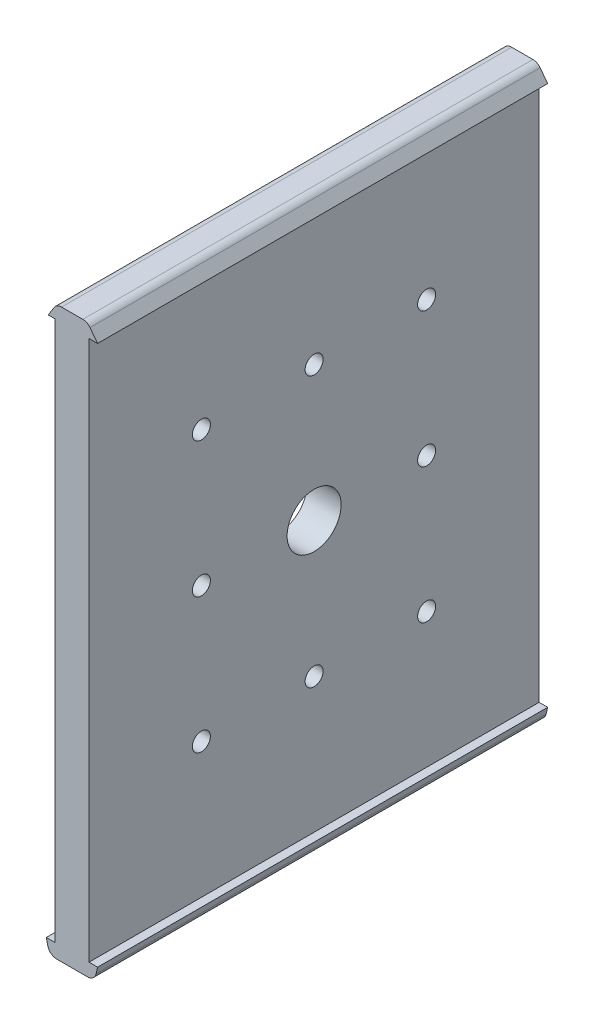
from build123d import *

# Parameters (mm, degrees)
RESSALTO_EXTRUS_O1_DEPTH   = 160
ESBO_O2_W                  = 7.6
ESBO_O2_H                  = 120
CORTE_EXTRUS_O1_DEPTH      = 30
CORTE_EXTRUS_O2_DEPTH      = 30
F_3DSKETCH3_R              = 2
CORTE_EXTRUS_O3_DEPTH      = 70
ESBO_O3_R                  = 6
ESBO_O3_W                  = 45.015344868
ESBO_O3_H                  = 129.478543367
ESBO_O3_W_2                = 37.192593828
CORTE_EXTRUS_O4_DEPTH      = 41
CORTE_EXTRUS_O4_DEPTH_BACK = 22


with BuildPart() as part:
    # Esboço1 → Ressalto-extrusão1 (new body)
    with BuildSketch(Plane.XY):
        with BuildLine():
            Line((-3.8, 21.821375341), (-3.8, -98.178624659))
            Line((-3.8, -98.178624659), (-5.7, -98.178624659))
            Line((-5.7, -98.178624659), (-5.360626179, -99.63308389))
            ThreePointArc((-5.360626179, -99.63308389), (-4.656141559, -100.745296045), (-3.41294376, -101.178624659))
            Line((-3.41294376, -101.178624659), (3.41294376, -101.178624659))
            ThreePointArc((3.41294376, -101.178624659), (4.656141559, -100.745296045), (5.360626179, -99.63308389))
            Line((5.360626179, -99.63308389), (5.7, -98.178624659))
            Line((5.7, -98.178624659), (3.8, -98.178624659))
            Line((3.8, -98.178624659), (3.8, 21.821375341))
            Line((3.8, 21.821375341), (5.7, 21.821375341))
            Line((5.7, 21.821375341), (4.013268169, 24.033911877))
            ThreePointArc((4.013268169, 24.033911877), (3.310139149, 24.613730366), (2.422747768, 24.821375341))
            Line((2.422747768, 24.821375341), (-2.297792791, 24.821375341))
            ThreePointArc((-2.297792791, 24.821375341), (-3.27177376, 24.568189891), (-3.999156919, 23.872736414))
            Line((-3.999156919, 23.872736414), (-5.266799243, 21.821375341))
            Line((-5.266799243, 21.821375341), (-3.8, 21.821375341))
        make_face()
    extrude(amount=RESSALTO_EXTRUS_O1_DEPTH)

    # Esboço2 → Corte-extrusão1 (cut)
    with BuildSketch(Plane.XY):
        with Locations((0, -38.178624659)):
            Rectangle(ESBO_O2_W, ESBO_O2_H)
    extrude(amount=CORTE_EXTRUS_O1_DEPTH, mode=Mode.SUBTRACT)

    # 3DSketch2 → Corte-extrusão2 (cut)
    with BuildSketch(Plane(origin=(-3.8, 21.821375341, 160), x_dir=(0.0632066956560733, -0.9980004577274705, 0), z_dir=(0, 0, -1))):
        Polygon((0, 0), (0.480370887, -7.584803479), (120.240425814, 0), (119.760054927, 7.584803479), align=None)
    extrude(amount=CORTE_EXTRUS_O2_DEPTH, mode=Mode.SUBTRACT)

    # 3DSketch3 → Corte-extrusão3 (cut)
    with BuildSketch(Plane(origin=(3.8, -38.178624659, 80), x_dir=(0, 0.7676852805184269, 0.6408270516101394), z_dir=(1, 0, 0))):
        with Locations(Location((0, 0, 0), (0, 0, 140.146481665))):
            Circle(F_3DSKETCH3_R)
        with Locations(Location((23.030558416, -19.224811548, 0), (0, 0, 140.146481665))):
            Circle(F_3DSKETCH3_R)
        with Locations(Location((-23.030558416, 19.224811548, 0), (0, 0, 140.146481665))):
            Circle(F_3DSKETCH3_R)
        with Locations(Location((-39.051234706, 0.032679535, 0), (0, 0, 140.146481665))):
            Circle(F_3DSKETCH3_R)
        with Locations(Location((-16.02067629, -19.192132013, 0), (0, 0, 140.146481665))):
            Circle(F_3DSKETCH3_R)
        with Locations(Location((7.009882125, -38.416943561, 0), (0, 0, 140.146481665))):
            Circle(F_3DSKETCH3_R)
        with Locations(Location((-6.982602808, 38.449623097, 0), (0, 0, 140.146481665))):
            Circle(F_3DSKETCH3_R)
        with Locations(Location((16.047955607, 19.224811548, 0), (0, 0, 140.146481665))):
            Circle(F_3DSKETCH3_R)
        with Locations(Location((39.078514023, 0, 0), (0, 0, 140.146481665))):
            Circle(F_3DSKETCH3_R)
    extrude(amount=-CORTE_EXTRUS_O3_DEPTH, mode=Mode.SUBTRACT)

    # Esboço3 → Corte-extrusão4 (cut, two sides)
    with BuildSketch(Plane(origin=(0, 0, 0), x_dir=(0, 0, -1), z_dir=(1, 0, 0))) as corte_extrus_o4_sk:
        with Locations(Location((-80, -38.178624659, 0), (0, 0, 270))):
            Circle(ESBO_O3_R)
        with Locations((-7.492327566, -39.917896343)):
            Rectangle(ESBO_O3_W, ESBO_O3_H)
        with Locations((-148.596296914, -39.917896343)):
            Rectangle(ESBO_O3_W_2, ESBO_O3_H)
    extrude(amount=CORTE_EXTRUS_O4_DEPTH, mode=Mode.SUBTRACT)
    extrude(corte_extrus_o4_sk.sketch, amount=-CORTE_EXTRUS_O4_DEPTH_BACK, mode=Mode.SUBTRACT)


solid = part.part
